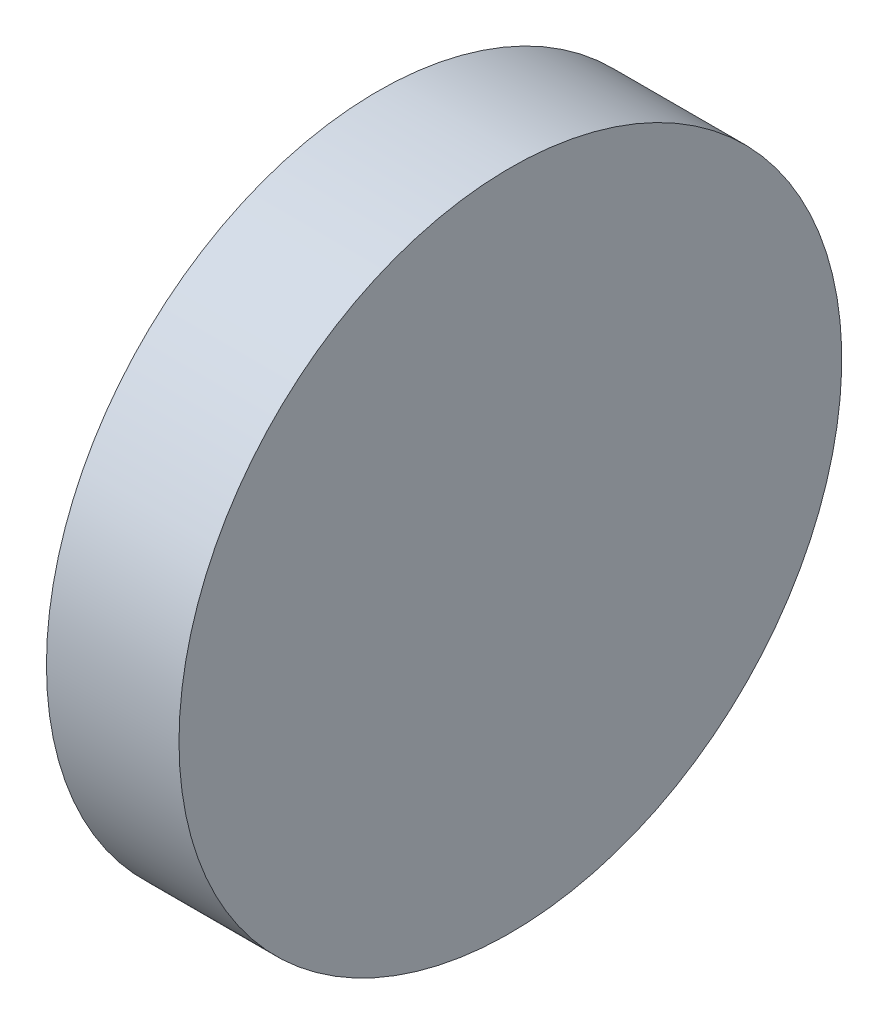
from build123d import *

# Parameters (mm, degrees)
SKETCH_1_W = 2
SKETCH_1_H = 5


with BuildPart() as part:
    # 草图1 → 旋转1 (revolve)
    with BuildSketch(Plane.XY, mode=Mode.PRIVATE) as revolve_1_sk:
        with Locations((105.062856197, 33.41727174)):
            Rectangle(SKETCH_1_W, SKETCH_1_H)
    revolve(revolve_1_sk.sketch.rotate(Axis((101.600320797, 30.91727174, 0), (1, 0, 0)), 90), axis=Axis((101.600320797, 30.91727174, 0), (1, 0, 0)))  # turned: the seam where the file's is


solid = part.part
